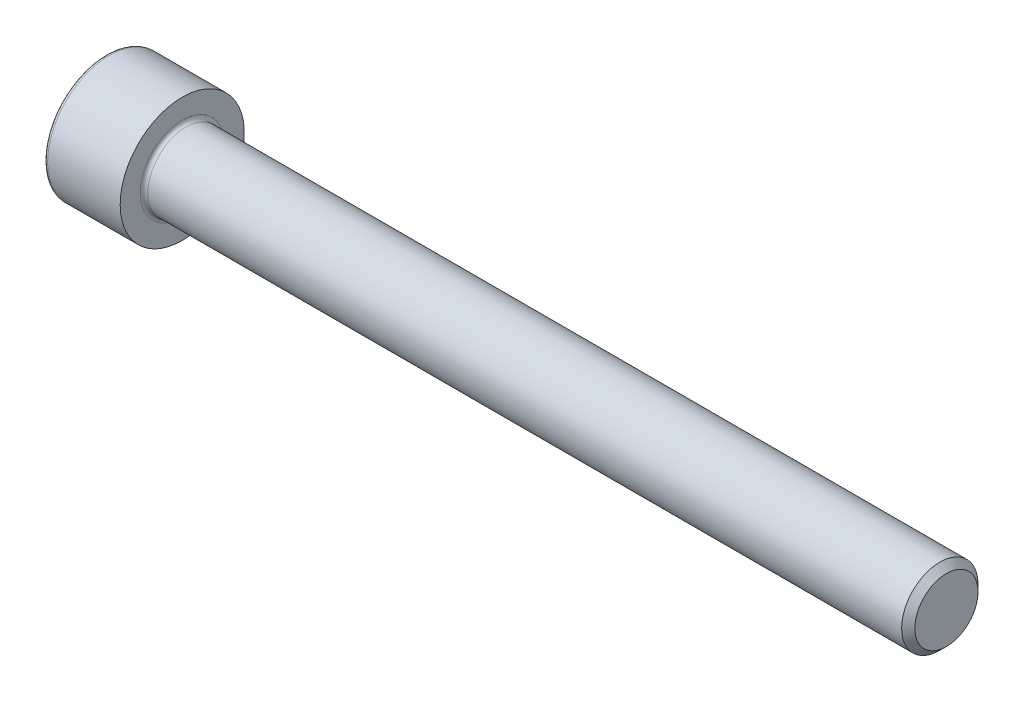
from build123d import *

# Parameters (mm, degrees)
FILLET1_R   = 0.4
FILLET2_R   = 0.4
HEX_2_DEPTH = 4


with BuildPart() as part:
    # BodySke → Base-Revolve (revolve)
    with BuildSketch(Plane.XY):
        Polygon((0, 0), (0, 6.5), (8, 6.5), (8, 4), (87.3095, 4), (88, 3.3095), (88, 0), align=None)
    revolve(axis=Axis((-31.75, 0, 0), (1, 0, 0)))

    # Fillet1
    fillet1_edges = [part.edges().sort_by_distance(p)[0] for p in [
        (8, -4, 0),
    ]]
    fillet(fillet1_edges, radius=FILLET1_R)

    # Fillet2
    fillet2_edges = [part.edges().sort_by_distance(p)[0] for p in [
        (0, -6.5, 0),
    ]]
    fillet(fillet2_edges, radius=FILLET2_R)

    # Sketch2 → Hex-PreBroach (revolve, cut)
    with BuildSketch(Plane.XY):
        Polygon((0, 3.0475), (4, 3.0475), (5.759474945, 0), (0, 0), align=None)
    revolve(axis=Axis((0, 0, 0), (1, 0, 0)), mode=Mode.SUBTRACT)

    # Sketch3 → Hex 2 (cut)
    with BuildSketch(Plane(origin=(0, 0, 0), x_dir=(0, 0.5, 0.866025404), z_dir=(-1, 0, 0))):
        Polygon((1.759474945, 3.0475), (-1.759474945, 3.0475), (-3.518949891, 0), (-1.759474945, -3.0475), (1.759474945, -3.0475), (3.518949891, 0), align=None)
    extrude(amount=-HEX_2_DEPTH, mode=Mode.SUBTRACT)


solid = part.part
